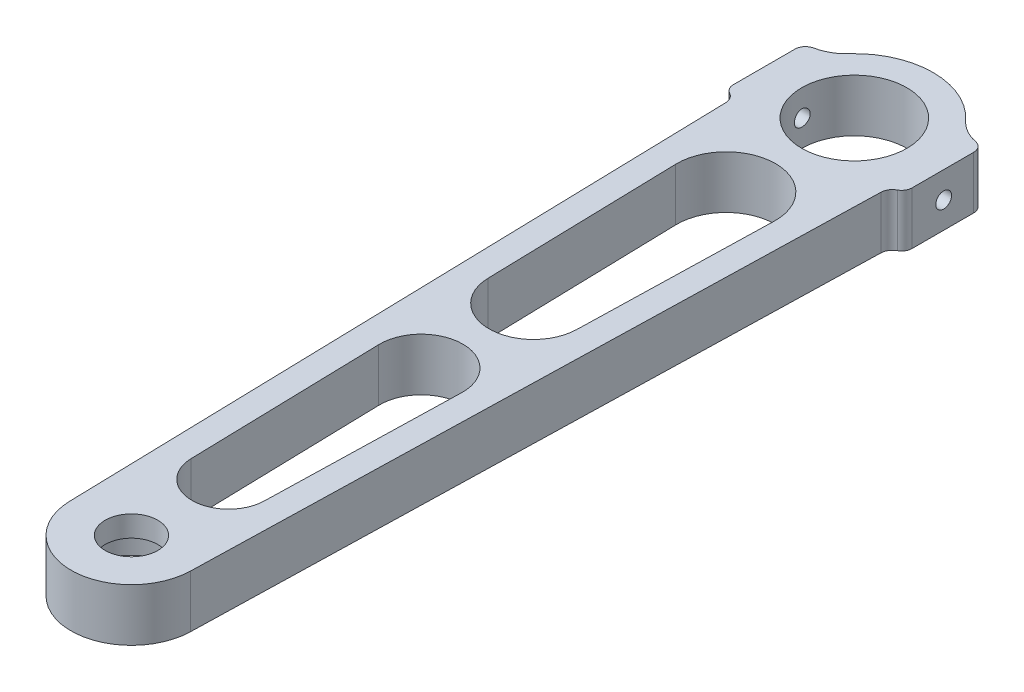
from build123d import *

# Parameters (mm, degrees)
SKETCH1_R           = 10
BOSS_EXTRUDE1_DEPTH = 10
SKETCH2_R           = 9.5
CUT_EXTRUDE1_DEPTH  = 6
SKETCH3_R           = 5
CUT_EXTRUDE2_DEPTH  = 11
CUT_EXTRUDE4_DEPTH  = 11
FILLET1_R           = 2
M4_TAPPED_HOLE1_D   = 3


with BuildPart() as part:
    # Sketch1 → Boss-Extrude1 (new body)
    with BuildSketch(Plane(origin=(0, 0, 0), x_dir=(1, 0, 0), z_dir=(0, 1, 0))):
        with BuildLine():
            Line((-14.758244484, -9.68540076), (-11.496273776, -137.792727273))
            ThreePointArc((-11.496273776, -137.792727273), (0, -149), (11.496273776, -137.792727273))
            Line((11.496273776, -137.792727273), (14.758244484, -9.68540076))
            ThreePointArc((14.758244484, -9.68540076), (15.434637081, -8.136753315), (17, -7.5))
            Line((17, -7.5), (17, 7.5))
            ThreePointArc((17, 7.5), (13.764151011, 8.182075624), (11.078928313, 10.112237509))
            ThreePointArc((11.078928313, 10.112237509), (0, 15), (-11.078928313, 10.112237509))
            ThreePointArc((-11.078928313, 10.112237509), (-13.764151011, 8.182075624), (-17, 7.5))
            Line((-17, 7.5), (-17, -7.5))
            ThreePointArc((-17, -7.5), (-15.434637081, -8.136753315), (-14.758244484, -9.68540076))
        make_face()
        Circle(SKETCH1_R, mode=Mode.SUBTRACT)
    extrude(amount=BOSS_EXTRUDE1_DEPTH)

    # Sketch2 → Cut-Extrude1 (cut)
    with BuildSketch(Plane(origin=(0, 0, 0), x_dir=(1, 0, 0), z_dir=(0, 1, 0))):
        with Locations((0, -137.5)):
            Circle(SKETCH2_R)
    extrude(amount=CUT_EXTRUDE1_DEPTH, mode=Mode.SUBTRACT)

    # Sketch3 → Cut-Extrude2 (cut, through all)
    with BuildSketch(Plane(origin=(0, 0, 0), x_dir=(-1, 0, 0), z_dir=(0, -1, 0))):
        with Locations((0, -137.5)):
            Circle(SKETCH3_R)
    extrude(amount=-CUT_EXTRUDE2_DEPTH, mode=Mode.SUBTRACT)

    # Sketch4 → Cut-Extrude4 (cut, through all)
    with BuildSketch(Plane(origin=(0, 0, 0), x_dir=(1, 0, 0), z_dir=(0, 1, 0))):
        with BuildLine():
            Line((-7.90050824, -82.580601653), (-6.96789079, -119.207272727))
            ThreePointArc((-6.96789079, -119.207272727), (0, -126), (6.96789079, -119.207272727))
            Line((6.96789079, -119.207272727), (7.90050824, -82.580601653))
            ThreePointArc((7.90050824, -82.580601653), (0, -74.476363636), (-7.90050824, -82.580601653))
        make_face()
        with BuildLine():
            Line((-9.376393506, -24.618181818), (-8.443776056, -61.244852893))
            ThreePointArc((-8.443776056, -61.244852893), (0, -69.476363636), (8.443776056, -61.244852893))
            Line((8.443776056, -61.244852893), (9.376393506, -24.618181818))
            ThreePointArc((9.376393506, -24.618181818), (0, -15), (-9.376393506, -24.618181818))
        make_face()
    extrude(amount=CUT_EXTRUDE4_DEPTH, mode=Mode.SUBTRACT)

    # Fillet1
    fillet1_edges = [part.edges().sort_by_distance(p)[0] for p in [
        (17, 5, -7.5),
        (17, 5, 7.5),
        (-17, 5, 7.5),
        (-17, 5, -7.5),
    ]]
    fillet(fillet1_edges, radius=FILLET1_R)

    # M4 Tapped Hole1 (through all)
    with Locations(Plane.ZY.offset(17)):
        with Locations((0, 5)):
            Hole(M4_TAPPED_HOLE1_D / 2)


solid = part.part
